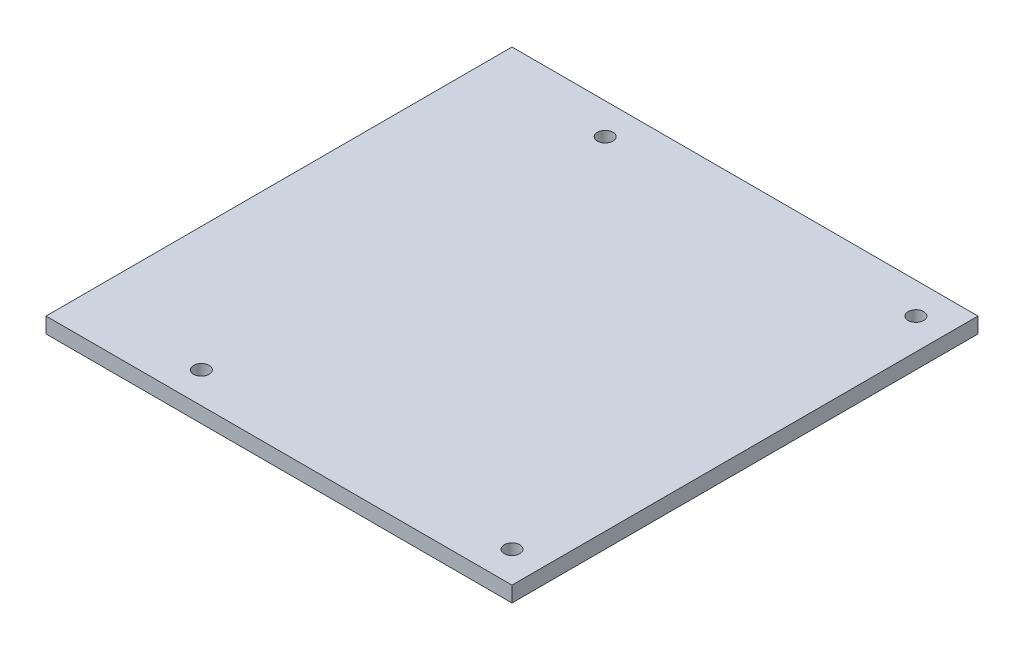
from build123d import *

# Parameters (mm, degrees)
CROQUIS1_W              = 150
CROQUIS1_H              = 75
CROQUIS1_R              = 2.5
SALIENTE_EXTRUIR1_DEPTH = 5


with BuildPart() as part:
    # Croquis1 → Saliente-Extruir1 (new body)
    with BuildSketch(Plane(origin=(0, 0, 0), x_dir=(1, 0, 0), z_dir=(0, 1, 0))):
        with Locations((-7.768891086, -79.955857637)):
            Rectangle(CROQUIS1_W, CROQUIS1_H)
        with Locations((-42.768891086, -107.455857637)):
            Circle(CROQUIS1_R, mode=Mode.SUBTRACT)
        with Locations((57.231108914, -107.455857637)):
            Circle(CROQUIS1_R, mode=Mode.SUBTRACT)
        with Locations((-7.768891086, -4.955857637)):
            Rectangle(CROQUIS1_W, CROQUIS1_H)
        with Locations((-42.768891086, 22.544142363)):
            Circle(CROQUIS1_R, mode=Mode.SUBTRACT)
        with Locations((57.231108914, 22.544142363)):
            Circle(CROQUIS1_R, mode=Mode.SUBTRACT)
    extrude(amount=SALIENTE_EXTRUIR1_DEPTH)


solid = part.part
